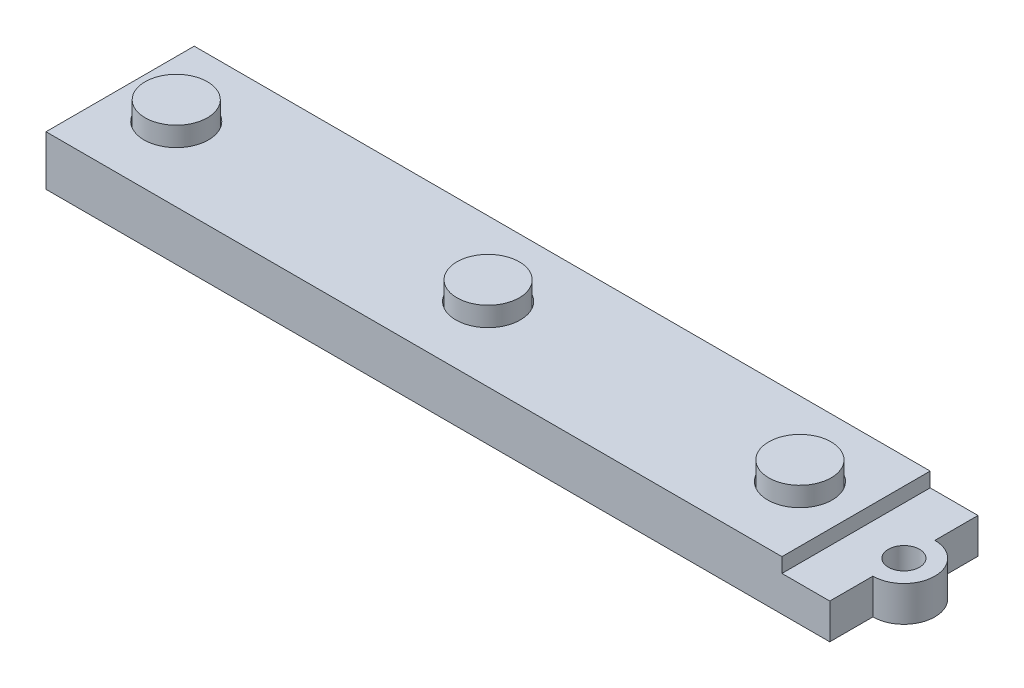
from build123d import *

# Parameters (mm, degrees)
SKETCH1_W           = 99.568
SKETCH1_H           = 18.1102
BOSS_EXTRUDE1_DEPTH = 6.096
SKETCH2_W           = 9.652
SKETCH2_H           = 18.1102
CUT_EXTRUDE1_DEPTH  = 1.778
SKETCH3_R           = 1.905
CUT_EXTRUDE2_DEPTH  = 5.318
SKETCH4_R           = 3.937
CUT_EXTRUDE3_DEPTH  = 1.27
SKETCH5_W           = 82.55
SKETCH5_H           = 12.7
BOSS_EXTRUDE2_DEPTH = 1.27
CUT_EXTRUDE4_DEPTH  = 6.588
SKETCH8_R           = 3.81
BOSS_EXTRUDE3_DEPTH = 3.556


with BuildPart() as part:
    # Sketch1 → Boss-Extrude1 (new body)
    with BuildSketch(Plane(origin=(0, 0, 0), x_dir=(1, 0, 0), z_dir=(0, 1, 0))):
        with Locations((-66.378666667, 25.894273737)):
            Rectangle(SKETCH1_W, SKETCH1_H)
    extrude(amount=BOSS_EXTRUDE1_DEPTH)

    # Sketch2 → Cut-Extrude1 (cut)
    with BuildSketch(Plane(origin=(0, 6.096, 0), x_dir=(1, 0, 0), z_dir=(0, 1, 0))):
        with Locations((-21.420666667, 25.894273737)):
            Rectangle(SKETCH2_W, SKETCH2_H)
    extrude(amount=-CUT_EXTRUDE1_DEPTH, mode=Mode.SUBTRACT)

    # Sketch3 → Cut-Extrude2 (cut, through all)
    with BuildSketch(Plane(origin=(0, 4.318, 0), x_dir=(1, 0, 0), z_dir=(0, 1, 0))):
        with Locations((-20.404666667, 25.894273737)):
            Circle(SKETCH3_R)
    extrude(amount=-CUT_EXTRUDE2_DEPTH, mode=Mode.SUBTRACT)

    # Sketch4 → Cut-Extrude3 (cut)
    with BuildSketch(Plane(origin=(0, 6.096, 0), x_dir=(1, 0, 0), z_dir=(0, 1, 0))):
        with Locations((-33.104666667, 25.894273737)):
            Circle(SKETCH4_R)
        with Locations((-71.204666667, 25.894273737)):
            Circle(SKETCH4_R)
        with Locations((-109.304666667, 25.894273737)):
            Circle(SKETCH4_R)
    extrude(amount=-CUT_EXTRUDE3_DEPTH, mode=Mode.SUBTRACT)

    # Sketch5 → Boss-Extrude2 (add)
    with BuildSketch(Plane.XZ):
        with Locations((-71.204666667, -25.894273737)):
            Rectangle(SKETCH5_W, SKETCH5_H)
    extrude(amount=BOSS_EXTRUDE2_DEPTH)

    # Sketch7 → Cut-Extrude4 (cut, through all)
    with BuildSketch(Plane(origin=(0, 4.318, 0), x_dir=(1, 0, 0), z_dir=(0, 1, 0))):
        with BuildLine():
            Line((-16.594666667, 34.949373737), (-20.404666667, 34.949373737))
            Line((-20.404666667, 34.949373737), (-20.404666667, 29.680045052))
            ThreePointArc((-20.404666667, 29.680045052), (-16.618895352, 25.894273737), (-20.404666667, 22.108502422))
            Line((-20.404666667, 22.108502422), (-20.404666667, 16.839173737))
            Line((-20.404666667, 16.839173737), (-16.594666667, 16.839173737))
            Line((-16.594666667, 16.839173737), (-16.594666667, 34.949373737))
        make_face()
    extrude(amount=-CUT_EXTRUDE4_DEPTH, mode=Mode.SUBTRACT)

    # Sketch8 → Boss-Extrude3 (add)
    with BuildSketch(Plane(origin=(0, 4.826, 0), x_dir=(1, 0, 0), z_dir=(0, 1, 0))):
        with Locations((-33.104666667, 25.894273737)):
            Circle(SKETCH8_R)
        with Locations((-71.204666667, 25.894273737)):
            Circle(SKETCH8_R)
        with Locations((-109.304666667, 25.894273737)):
            Circle(SKETCH8_R)
    extrude(amount=BOSS_EXTRUDE3_DEPTH)


solid = part.part
